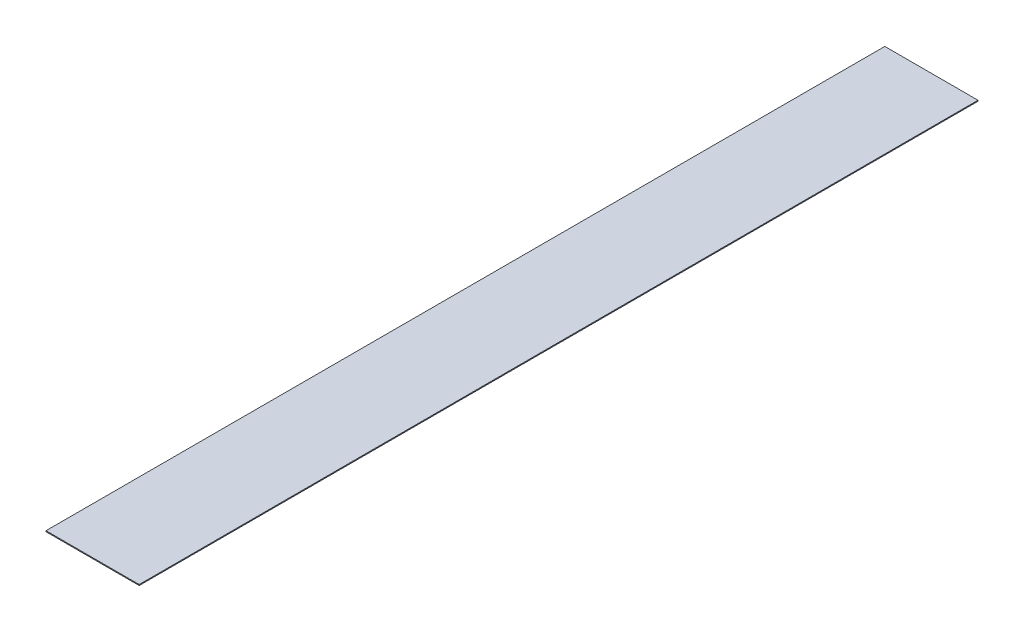
from build123d import *

# Parameters (mm, degrees)
SKETCH1_W           = 50.8
SKETCH1_H           = 457.2
BOSS_EXTRUDE1_DEPTH = 0.508


with BuildPart() as part:
    # Sketch1 → Boss-Extrude1 (new body)
    with BuildSketch(Plane(origin=(0, 0, 0), x_dir=(1, 0, 0), z_dir=(0, 1, 0))):
        with Locations((0, 228.6)):
            Rectangle(SKETCH1_W, SKETCH1_H)
    extrude(amount=BOSS_EXTRUDE1_DEPTH)


solid = part.part
